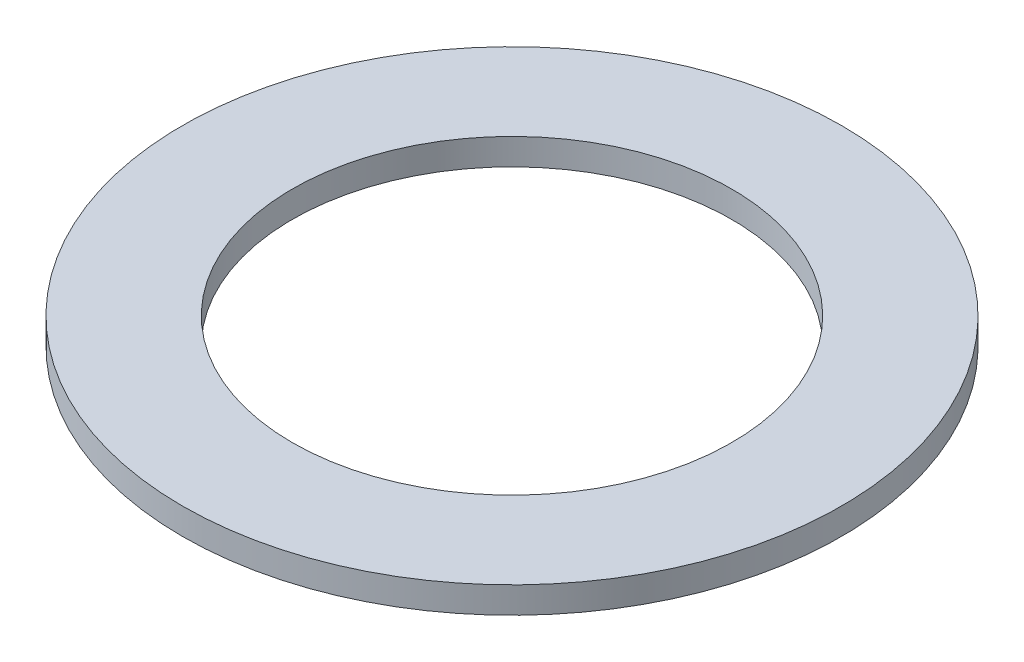
from build123d import *

# Parameters (mm, degrees)
SKETCH1_R           = 9.525
BOSS_EXTRUDE1_DEPTH = 0.762
SKETCH5_R           = 6.35
CUT_EXTRUDE1_DEPTH  = 1.762


with BuildPart() as part:
    # Sketch1 → Boss-Extrude1 (new body)
    with BuildSketch(Plane(origin=(0, 0, 0), x_dir=(1, 0, 0), z_dir=(0, 1, 0))):
        Circle(SKETCH1_R)
    extrude(amount=BOSS_EXTRUDE1_DEPTH)

    # Sketch5 → Cut-Extrude1 (cut, through all)
    with BuildSketch(Plane(origin=(0, 0.762, 0), x_dir=(-1, 0, 0), z_dir=(0, 1, 0))):
        Circle(SKETCH5_R)
    extrude(amount=-CUT_EXTRUDE1_DEPTH, mode=Mode.SUBTRACT)


solid = part.part
